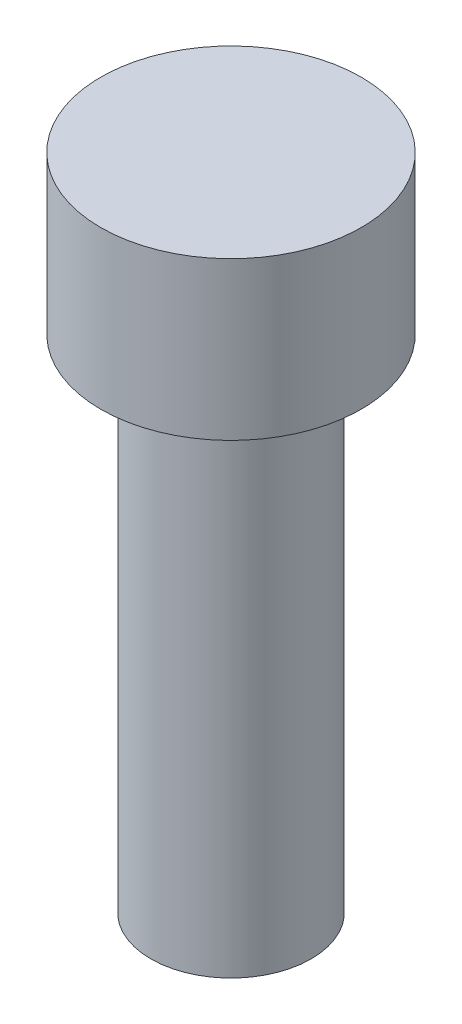
from build123d import *


with BuildPart() as part:
    # Esquisse1 → Révolution1 (revolve)
    with BuildSketch(Plane.XY):
        Polygon((0, 0), (6.5, 0), (6.5, -7.852106722), (4, -7.852106722), (4, -32.852106722), (0, -32.852106722), align=None)
    revolve(axis=Axis((0, 0, 0), (0, -1, 0)))


solid = part.part
